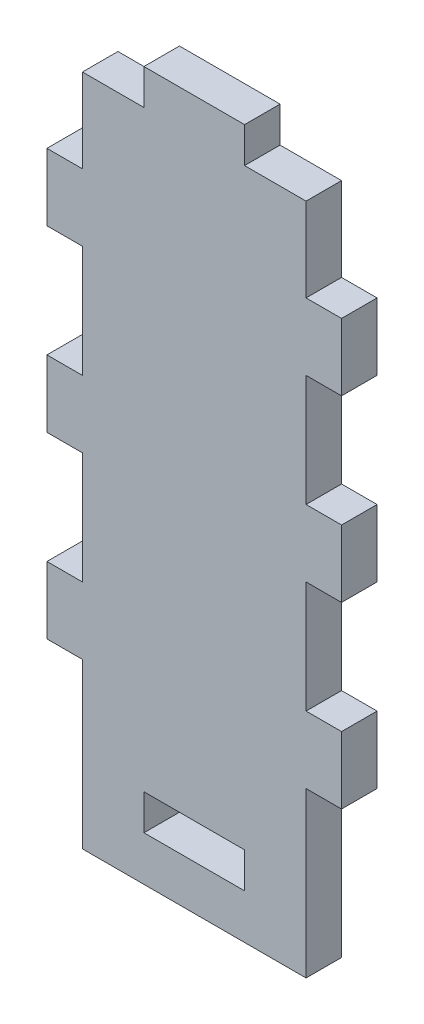
from build123d import *

# Parameters (mm, degrees)
SKETCH1_W           = 9
SKETCH1_H           = 3.175
BOSS_EXTRUDE2_DEPTH = 1.5875


with BuildPart() as part:
    # Sketch1 → Boss-Extrude2 (new body, symmetric)
    with BuildSketch(Plane.XY):
        Polygon((0, 14.675), (3.175, 14.675), (3.175, 20.675), (0, 20.675), (0, 30.675), (3.175, 30.675), (3.175, 36.675), (0, 36.675), (0, 46.675), (3.175, 46.675), (3.175, 52.675), (0, 52.675), (0, 60.175), (-5.5, 60.175), (-5.5, 63.35), (-14.5, 63.35), (-14.5, 60.175), (-20, 60.175), (-20, 52.675), (-23.175, 52.675), (-23.175, 46.675), (-20, 46.675), (-20, 36.675), (-23.175, 36.675), (-23.175, 30.675), (-20, 30.675), (-20, 20.675), (-23.175, 20.675), (-23.175, 14.675), (-20, 14.675), (-20, 7.175), (-20, 0), (0, 0), (0, 7.175), align=None)
        with Locations((-10, 5.5875)):
            Rectangle(SKETCH1_W, SKETCH1_H, mode=Mode.SUBTRACT)
    extrude(amount=BOSS_EXTRUDE2_DEPTH, both=True)


solid = part.part
